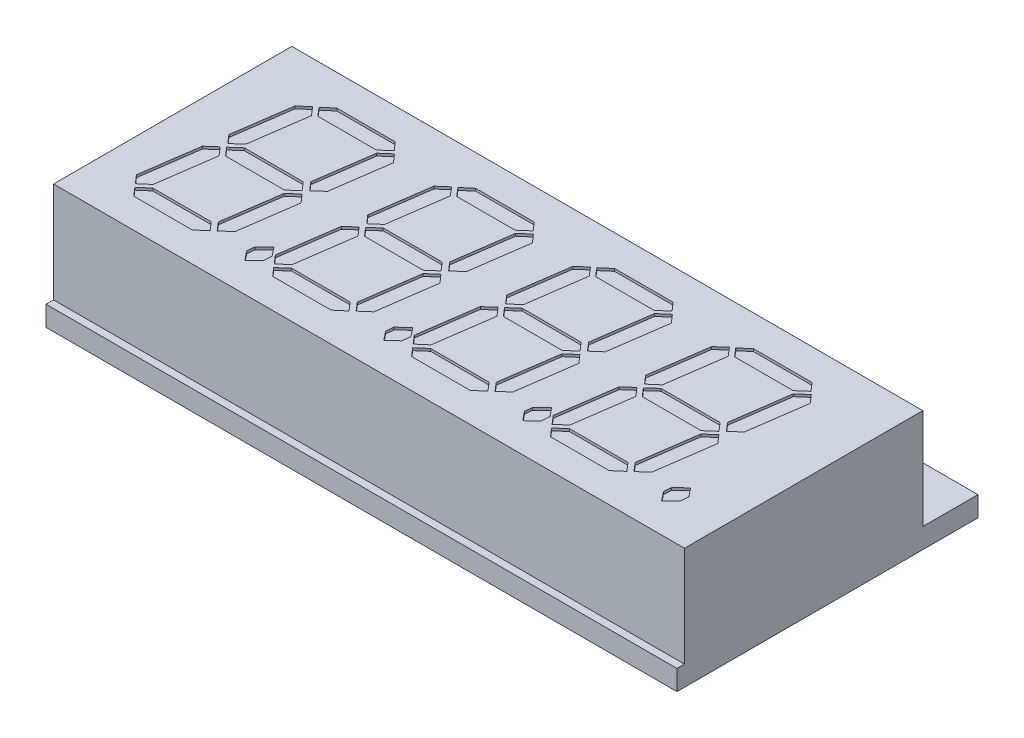
from build123d import *

# Parameters (mm, degrees)
SKETCH1_W           = 50.3
SKETCH1_H           = 19
BOSS_EXTRUDE1_DEPTH = 8
SKETCH3_W           = 50.3
SKETCH3_H           = 24
BOSS_EXTRUDE2_DEPTH = 1.6
CUT_EXTRUDE1_DEPTH  = 0.2


with BuildPart() as part:
    # Sketch1 → Boss-Extrude1 (new body)
    with BuildSketch(Plane(origin=(0, 0, 0), x_dir=(1, 0, 0), z_dir=(0, 1, 0))):
        with Locations((25.15, 9.5)):
            Rectangle(SKETCH1_W, SKETCH1_H)
    extrude(amount=BOSS_EXTRUDE1_DEPTH)

    # Sketch3 → Boss-Extrude2 (add)
    with BuildSketch(Plane.XZ):
        with Locations((25.15, -11.4)):
            Rectangle(SKETCH3_W, SKETCH3_H)
    extrude(amount=BOSS_EXTRUDE2_DEPTH)

    # Sketch6 → Cut-Extrude1 (cut)
    with BuildSketch(Plane(origin=(0, 8, 0), x_dir=(1, 0, 0), z_dir=(0, 1, 0))):
        Polygon((11.284901925, 15.877434563), (10.520105341, 15.210490741), (5.856648727, 15.210490741), (5.287557666, 15.877434563), (6.05235425, 16.52892795), (10.715810864, 16.52892795), align=None)
        Polygon((4.914172128, 10.400254985), (4.151950617, 9.74103638), (3.582859556, 10.395104839), (4.236928015, 15.009635072), (4.991424309, 15.668853677), (5.565665515, 14.994184636), align=None)
        Polygon((4.002596402, 3.936822572), (3.24037489, 3.28017904), (2.671283829, 3.939397645), (3.325352288, 8.546202659), (4.079848582, 9.207996337), (4.654089788, 8.541052514), align=None)
        Polygon((9.469475689, 3.007221337), (8.704679105, 2.35572795), (4.041222492, 2.35572795), (3.472131431, 3.007221337), (4.236928015, 3.674165159), (8.900384628, 3.674165159), align=None)
        Polygon((10.520105341, 3.939397645), (9.765609047, 3.28017904), (9.191367841, 3.952273008), (9.842861227, 8.548777732), (10.605082739, 9.207996337), (11.1741738, 8.553927877), align=None)
        Polygon((11.431681067, 10.40540513), (10.677184774, 9.74103638), (10.102943567, 10.407980203), (10.754436954, 15.012210145), (11.516658466, 15.668853677), (12.085749527, 15.012210145), align=None)
        Polygon((10.378476343, 9.44232795), (9.613679759, 8.783109345), (4.929622564, 8.783109345), (4.360531503, 9.44232795), (5.107302579, 10.101546555), (9.809385282, 10.101546555), align=None)
        Polygon((13.644698524, 3.066448008), (12.897927448, 2.35572795), (12.321111169, 3.074173226), (12.375187695, 3.674165159), (13.147709498, 4.413211017), (13.703925195, 3.720516467), align=None)
        Polygon((22.359774483, 15.877434563), (21.594977899, 15.210490741), (16.931521285, 15.210490741), (16.362430224, 15.877434563), (17.127226809, 16.52892795), (21.790683422, 16.52892795), align=None)
        Polygon((15.989044686, 10.400254985), (15.226823175, 9.74103638), (14.657732114, 10.395104839), (15.311800573, 15.009635072), (16.066296867, 15.668853677), (16.640538073, 14.994184636), align=None)
        Polygon((15.07746896, 3.936822572), (14.315247448, 3.28017904), (13.746156387, 3.939397645), (14.400224846, 8.546202659), (15.15472114, 9.207996337), (15.728962346, 8.541052514), align=None)
        Polygon((20.544348248, 3.007221337), (19.779551663, 2.35572795), (15.11609505, 2.35572795), (14.547003989, 3.007221337), (15.311800573, 3.674165159), (19.975257186, 3.674165159), align=None)
        Polygon((21.594977899, 3.939397645), (20.840481605, 3.28017904), (20.266240399, 3.952273008), (20.917733785, 8.548777732), (21.679955297, 9.207996337), (22.249046358, 8.553927877), align=None)
        Polygon((22.506553625, 10.40540513), (21.752057332, 9.74103638), (21.177816125, 10.407980203), (21.829309512, 15.012210145), (22.591531024, 15.668853677), (23.160622085, 15.012210145), align=None)
        Polygon((21.453348902, 9.44232795), (20.688552317, 8.783109345), (16.004495123, 8.783109345), (15.435404061, 9.44232795), (16.182175137, 10.101546555), (20.884257841, 10.101546555), align=None)
        Polygon((24.719571082, 3.066448008), (23.972800006, 2.35572795), (23.395983727, 3.074173226), (23.450060253, 3.674165159), (24.222582056, 4.413211017), (24.778797753, 3.720516467), align=None)
        Polygon((33.434647041, 15.877434563), (32.669850457, 15.210490741), (28.006393843, 15.210490741), (27.437302782, 15.877434563), (28.202099367, 16.52892795), (32.86555598, 16.52892795), align=None)
        Polygon((27.063917245, 10.400254985), (26.301695733, 9.74103638), (25.732604672, 10.395104839), (26.386673131, 15.009635072), (27.141169425, 15.668853677), (27.715410631, 14.994184636), align=None)
        Polygon((26.152341518, 3.936822572), (25.390120006, 3.28017904), (24.821028945, 3.939397645), (25.475097404, 8.546202659), (26.229593698, 9.207996337), (26.803834904, 8.541052514), align=None)
        Polygon((31.619220806, 3.007221337), (30.854424221, 2.35572795), (26.190967608, 2.35572795), (25.621876547, 3.007221337), (26.386673131, 3.674165159), (31.050129745, 3.674165159), align=None)
        Polygon((32.669850457, 3.939397645), (31.915354163, 3.28017904), (31.341112957, 3.952273008), (31.992606343, 8.548777732), (32.754827855, 9.207996337), (33.323918916, 8.553927877), align=None)
        Polygon((33.581426184, 10.40540513), (32.82692989, 9.74103638), (32.252688684, 10.407980203), (32.90418207, 15.012210145), (33.666403582, 15.668853677), (34.235494643, 15.012210145), align=None)
        Polygon((32.52822146, 9.44232795), (31.763424875, 8.783109345), (27.079367681, 8.783109345), (26.51027662, 9.44232795), (27.257047695, 10.101546555), (31.959130399, 10.101546555), align=None)
        Polygon((35.79444364, 3.066448008), (35.047672564, 2.35572795), (34.470856285, 3.074173226), (34.524932811, 3.674165159), (35.297454614, 4.413211017), (35.853670311, 3.720516467), align=None)
        Polygon((44.509519599, 15.877434563), (43.744723015, 15.210490741), (39.081266402, 15.210490741), (38.512175341, 15.877434563), (39.276971925, 16.52892795), (43.940428538, 16.52892795), align=None)
        Polygon((38.138789803, 10.400254985), (37.376568291, 9.74103638), (36.80747723, 10.395104839), (37.461545689, 15.009635072), (38.216041983, 15.668853677), (38.790283189, 14.994184636), align=None)
        Polygon((37.227214076, 3.936822572), (36.464992564, 3.28017904), (35.895901503, 3.939397645), (36.549969963, 8.546202659), (37.304466256, 9.207996337), (37.878707463, 8.541052514), align=None)
        Polygon((42.694093364, 3.007221337), (41.929296779, 2.35572795), (37.265840166, 2.35572795), (36.696749105, 3.007221337), (37.461545689, 3.674165159), (42.125002303, 3.674165159), align=None)
        Polygon((43.744723015, 3.939397645), (42.990226721, 3.28017904), (42.415985515, 3.952273008), (43.067478902, 8.548777732), (43.829700413, 9.207996337), (44.398791474, 8.553927877), align=None)
        Polygon((44.656298742, 10.40540513), (43.901802448, 9.74103638), (43.327561242, 10.407980203), (43.979054628, 15.012210145), (44.74127614, 15.668853677), (45.310367201, 15.012210145), align=None)
        Polygon((43.603094018, 9.44232795), (42.838297434, 8.783109345), (38.154240239, 8.783109345), (37.585149178, 9.44232795), (38.331920253, 10.101546555), (43.034002957, 10.101546555), align=None)
        Polygon((46.869316198, 3.066448008), (46.122545123, 2.35572795), (45.545728843, 3.074173226), (45.59980537, 3.674165159), (46.372327172, 4.413211017), (46.92854287, 3.720516467), align=None)
    extrude(amount=-CUT_EXTRUDE1_DEPTH, mode=Mode.SUBTRACT)


solid = part.part
